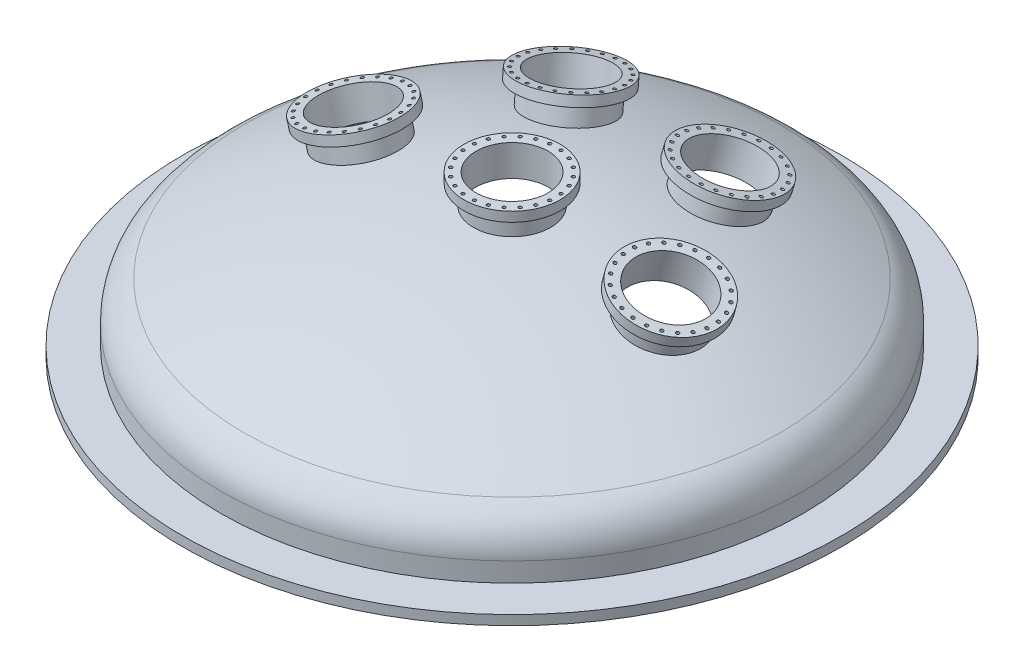
from build123d import *
from build123d.topology import SkipClean

# Parameters (mm, degrees)
REVOLVE6_ANGLE           = 180
REVOLVE7_ANGLE           = 180
CUT_EXTRUDE4_DEPTH       = 1301.690466813
SKETCH11_R               = 95.25
CUT_EXTRUDE5_DEPTH       = 1345.011112617
SKETCH12_R               = 95.25
CUT_EXTRUDE6_DEPTH       = 1233.519644311
CUT_EXTRUDE7_REACH       = 1302.69
SKETCH13_R               = 4.2164
CIRPATTERN1_COUNT        = 13
CIRPATTERN1_ANGLE        = 180
CUT_EXTRUDE8_REACH       = 1234.52
SKETCH15_R               = 4.2164
CIRPATTERN2_COUNT        = 24
CUT_EXTRUDE9_REACH       = 1346.011
SKETCH16_R               = 4.2164
CIRPATTERN3_COUNT        = 24
MIRROR2_COPY_1_REACH     = 1302.69
MIRROR2_COPY_1_SKETCH_R  = 4.2164
MIRROR2_COPY_2_REACH     = 1302.69
MIRROR2_COPY_2_SKETCH_R  = 4.2164
MIRROR2_COPY_3_REACH     = 1302.69
MIRROR2_COPY_3_SKETCH_R  = 4.2164
MIRROR2_COPY_4_REACH     = 1302.69
MIRROR2_COPY_4_SKETCH_R  = 4.2164
MIRROR2_COPY_5_REACH     = 1302.69
MIRROR2_COPY_5_SKETCH_R  = 4.2164
MIRROR2_COPY_6_REACH     = 1302.69
MIRROR2_COPY_6_SKETCH_R  = 4.2164
MIRROR2_COPY_7_REACH     = 1302.69
MIRROR2_COPY_7_SKETCH_R  = 4.2164
MIRROR2_COPY_8_REACH     = 1302.69
MIRROR2_COPY_8_SKETCH_R  = 4.2164
MIRROR2_COPY_9_REACH     = 1302.69
MIRROR2_COPY_9_SKETCH_R  = 4.2164
MIRROR2_COPY_10_REACH    = 1302.69
MIRROR2_COPY_10_SKETCH_R = 4.2164
MIRROR2_COPY_11_REACH    = 1302.69
MIRROR2_COPY_11_SKETCH_R = 4.2164
MIRROR2_COPY_12_REACH    = 1302.69
MIRROR2_COPY_12_SKETCH_R = 4.2164
MIRROR2_COPY_13_REACH    = 1234.52
MIRROR2_COPY_13_SKETCH_R = 4.2164
MIRROR2_COPY_14_REACH    = 1234.52
MIRROR2_COPY_14_SKETCH_R = 4.2164
MIRROR2_COPY_15_REACH    = 1234.52
MIRROR2_COPY_15_SKETCH_R = 4.2164
MIRROR2_COPY_16_REACH    = 1234.52
MIRROR2_COPY_16_SKETCH_R = 4.2164
MIRROR2_COPY_17_REACH    = 1234.52
MIRROR2_COPY_17_SKETCH_R = 4.2164
MIRROR2_COPY_18_REACH    = 1234.52
MIRROR2_COPY_18_SKETCH_R = 4.2164
MIRROR2_COPY_19_REACH    = 1234.52
MIRROR2_COPY_19_SKETCH_R = 4.2164
MIRROR2_COPY_20_REACH    = 1234.52
MIRROR2_COPY_20_SKETCH_R = 4.2164
MIRROR2_COPY_21_REACH    = 1234.52
MIRROR2_COPY_21_SKETCH_R = 4.2164
MIRROR2_COPY_22_REACH    = 1234.52
MIRROR2_COPY_22_SKETCH_R = 4.2164
MIRROR2_COPY_23_REACH    = 1234.52
MIRROR2_COPY_23_SKETCH_R = 4.2164
MIRROR2_COPY_24_REACH    = 1234.52
MIRROR2_COPY_24_SKETCH_R = 4.2164
MIRROR2_COPY_25_REACH    = 1234.52
MIRROR2_COPY_25_SKETCH_R = 4.2164
MIRROR2_COPY_26_REACH    = 1234.52
MIRROR2_COPY_26_SKETCH_R = 4.2164
MIRROR2_COPY_27_REACH    = 1234.52
MIRROR2_COPY_27_SKETCH_R = 4.2164
MIRROR2_COPY_28_REACH    = 1234.52
MIRROR2_COPY_28_SKETCH_R = 4.2164
MIRROR2_COPY_29_REACH    = 1234.52
MIRROR2_COPY_29_SKETCH_R = 4.2164
MIRROR2_COPY_30_REACH    = 1234.52
MIRROR2_COPY_30_SKETCH_R = 4.2164
MIRROR2_COPY_31_REACH    = 1234.52
MIRROR2_COPY_31_SKETCH_R = 4.2164
MIRROR2_COPY_32_REACH    = 1234.52
MIRROR2_COPY_32_SKETCH_R = 4.2164
MIRROR2_COPY_33_REACH    = 1234.52
MIRROR2_COPY_33_SKETCH_R = 4.2164
MIRROR2_COPY_34_REACH    = 1234.52
MIRROR2_COPY_34_SKETCH_R = 4.2164
MIRROR2_COPY_35_REACH    = 1234.52
MIRROR2_COPY_35_SKETCH_R = 4.2164
MIRROR2_COPY_36_REACH    = 1234.52
MIRROR2_COPY_36_SKETCH_R = 4.2164
MIRROR2_COPY_37_REACH    = 1346.011
MIRROR2_COPY_37_SKETCH_R = 4.2164
MIRROR2_COPY_38_REACH    = 1346.011
MIRROR2_COPY_38_SKETCH_R = 4.2164
MIRROR2_COPY_39_REACH    = 1346.011
MIRROR2_COPY_39_SKETCH_R = 4.2164
MIRROR2_COPY_40_REACH    = 1346.011
MIRROR2_COPY_40_SKETCH_R = 4.2164
MIRROR2_COPY_41_REACH    = 1346.011
MIRROR2_COPY_41_SKETCH_R = 4.2164
MIRROR2_COPY_42_REACH    = 1346.011
MIRROR2_COPY_42_SKETCH_R = 4.2164
MIRROR2_COPY_43_REACH    = 1346.011
MIRROR2_COPY_43_SKETCH_R = 4.2164
MIRROR2_COPY_44_REACH    = 1346.011
MIRROR2_COPY_44_SKETCH_R = 4.2164
MIRROR2_COPY_45_REACH    = 1346.011
MIRROR2_COPY_45_SKETCH_R = 4.2164
MIRROR2_COPY_46_REACH    = 1346.011
MIRROR2_COPY_46_SKETCH_R = 4.2164
MIRROR2_COPY_47_REACH    = 1346.011
MIRROR2_COPY_47_SKETCH_R = 4.2164
MIRROR2_COPY_48_REACH    = 1346.011
MIRROR2_COPY_48_SKETCH_R = 4.2164
MIRROR2_COPY_49_REACH    = 1346.011
MIRROR2_COPY_49_SKETCH_R = 4.2164
MIRROR2_COPY_50_REACH    = 1346.011
MIRROR2_COPY_50_SKETCH_R = 4.2164
MIRROR2_COPY_51_REACH    = 1346.011
MIRROR2_COPY_51_SKETCH_R = 4.2164
MIRROR2_COPY_52_REACH    = 1346.011
MIRROR2_COPY_52_SKETCH_R = 4.2164
MIRROR2_COPY_53_REACH    = 1346.011
MIRROR2_COPY_53_SKETCH_R = 4.2164
MIRROR2_COPY_54_REACH    = 1346.011
MIRROR2_COPY_54_SKETCH_R = 4.2164
MIRROR2_COPY_55_REACH    = 1346.011
MIRROR2_COPY_55_SKETCH_R = 4.2164
MIRROR2_COPY_56_REACH    = 1346.011
MIRROR2_COPY_56_SKETCH_R = 4.2164
MIRROR2_COPY_57_REACH    = 1346.011
MIRROR2_COPY_57_SKETCH_R = 4.2164
MIRROR2_COPY_58_REACH    = 1346.011
MIRROR2_COPY_58_SKETCH_R = 4.2164
MIRROR2_COPY_59_REACH    = 1346.011
MIRROR2_COPY_59_SKETCH_R = 4.2164
MIRROR2_COPY_60_REACH    = 1346.011
MIRROR2_COPY_60_SKETCH_R = 4.2164


with BuildPart() as part:
    # Sketch2 → Revolve6 (revolve)
    with BuildSketch(Plane.ZY):
        with BuildLine():
            Line((-762, 0), (-762, 76.2))
            ThreePointArc((-762, 76.2), (-746.146387828, 132.632796575), (-703.224203775, 172.553764303))
            ThreePointArc((-703.224203775, 172.553764303), (-361.781052845, 299.706397644), (0, 342.9))
            Line((0, 342.9), (0, 349.25))
            ThreePointArc((0, 349.25), (-363.276015874, 305.877911683), (-706.130088915, 178.199854238))
            ThreePointArc((-706.130088915, 178.199854238), (-751.567405751, 135.939617508), (-768.35, 76.2))
            Line((-768.35, 76.2), (-768.35, 25.4))
            Line((-768.35, 25.4), (-869.95, 25.4))
            Line((-869.95, 25.4), (-869.95, 0))
            Line((-869.95, 0), (-762, 0))
        make_face()
    revolve6 = revolve(axis=Axis((0, 0, 0), (0, 1, 0)), revolution_arc=REVOLVE6_ANGLE)

    # Sketch3 → Revolve7 (revolve)
    with BuildSketch(Plane(origin=(0, 0, 0), x_dir=(0, 0, -1), z_dir=(1, 0, 0))):
        with BuildLine():
            Line((101.6, 345.901510846), (101.6, 396.701510846))
            Line((101.6, 396.701510846), (127, 396.701510846))
            Line((127, 396.701510846), (127, 422.101510846))
            Line((127, 422.101510846), (0, 422.101510846))
            Line((0, 422.101510846), (0, 349.25))
            ThreePointArc((0, 349.25), (50.827582029, 348.412650514), (101.6, 345.901510846))
        make_face()
    revolve7 = revolve(axis=Axis((0, -136.02863292, 0), (0, 1, 0)), revolution_arc=REVOLVE7_ANGLE)

    # Sketch4 → Revolve8 (revolve)
    with BuildSketch(Plane.XY):
        with BuildLine():
            Line((-418.937428738, 366.850224604), (-541.595014732, 333.924298678))
            Line((-541.595014732, 333.924298678), (-535.009829547, 309.392781479))
            Line((-535.009829547, 309.392781479), (-510.478312348, 315.977966664))
            Line((-510.478312348, 315.977966664), (-497.307941978, 266.914932266))
            ThreePointArc((-497.307941978, 266.914932266), (-448.922582728, 282.503429928), (-400.05, 296.489669829))
            Line((-400.05, 296.489669829), (-418.937428738, 366.850224604))
        make_face()
    revolve8 = revolve(axis=Axis((-524.069555167, 758.494574021, 0), (0.2592592592592594, -0.9658077637337258, 0)))

    # Sketch6 → Revolve9 (revolve)
    with BuildSketch(Plane(origin=(-157.461606048, -21.143582215, 0), x_dir=(0, 0, -1), z_dir=(0.9911048584771088, 0.13308328032878555, 0)), mode=Mode.PRIVATE) as revolve9_sk:
        with BuildLine():
            Line((447.455484953, 293.567777013), (458.953427339, 343.049463735))
            Line((458.953427339, 343.049463735), (483.6942707, 337.300492541))
            Line((483.6942707, 337.300492541), (489.443241894, 362.041335902))
            Line((489.443241894, 362.041335902), (365.739025088, 390.786191869))
            Line((365.739025088, 390.786191869), (349.25, 319.825254135))
            ThreePointArc((349.25, 319.825254135), (398.569029422, 307.505449514), (447.455484953, 293.567777013))
        make_face()
    revolve9 = revolve(revolve9_sk.sketch.rotate(Axis((-200.025, 295.836781022, -349.25), (0.12962962962962968, -0.9653846479520914, 0.22633744855967086)), 178.259198398), axis=Axis((-200.025, 295.836781022, -349.25), (0.12962962962962968, -0.9653846479520914, 0.22633744855967086)))

    # Sketch10 → Cut-Extrude4 (cut, through all)
    with BuildSketch(Plane(origin=(0, 422.101510846, 0), x_dir=(-1, 0, 0), z_dir=(0, 1, 0))):
        with BuildLine():
            Line((0, 95.25), (0, -95.25))
            ThreePointArc((0, -95.25), (95.25, 0), (0, 95.25))
        make_face()
    cut_extrude4 = extrude(amount=-CUT_EXTRUDE4_DEPTH, mode=Mode.SUBTRACT)

    # Sketch11 → Cut-Extrude5 (cut, through all)
    with BuildSketch(Plane(origin=(-60.073652349, 447.383687586, -104.890504101), x_dir=(-0.9915624837205597, -0.12620733077213464, 0.02958970323081933), z_dir=(-0.12962962962962965, 0.9653846479520914, -0.22633744855967086))):
        with Locations(Location((150.666311476, -272.500876674, 0), (0, 0, 90))):
            Circle(SKETCH11_R)
    cut_extrude5 = extrude(amount=-CUT_EXTRUDE5_DEPTH, mode=Mode.SUBTRACT)

    # Sketch12 → Cut-Extrude6 (cut, through all)
    with BuildSketch(Plane(origin=(-120.016348796, 447.091925564, 0), x_dir=(-0.9658077637337257, -0.2592592592592595, 0), z_dir=(-0.2592592592592595, 0.9658077637337258, 0))):
        with Locations((309.503703704, 0)):
            Circle(SKETCH12_R)
    cut_extrude6 = extrude(amount=-CUT_EXTRUDE6_DEPTH, mode=Mode.SUBTRACT)

    # Sketch13 → Cut-Extrude7 (cut, up to next)
    with BuildSketch(Plane(origin=(0, 422.101510846, 0), x_dir=(-1, 0, 0), z_dir=(0, 1, 0)), mode=Mode.PRIVATE) as cut_extrude7_sk1:
        with Locations(Location((15.068335208, -114.455369132, 0), (0, 0, 90))):
            Circle(SKETCH13_R)
    cut_extrude7_tool1 = extrude(cut_extrude7_sk1.sketch, amount=-CUT_EXTRUDE7_REACH, mode=Mode.PRIVATE) & part.part
    cut_extrude7 = cut_extrude7_tool1.solids().sort_by_distance((-15.068335, 422.101511, -114.455369))[0]
    add(cut_extrude7, mode=Mode.SUBTRACT)

    # CirPattern1: Cut-Extrude7 ×13 about axis, 1 skipped
    cirpattern1_axis = Axis((0, 0, 0), (0, 1, 0))
    add([cut_extrude7.rotate(cirpattern1_axis, i * CIRPATTERN1_ANGLE / (CIRPATTERN1_COUNT - 1)) for i in range(1, CIRPATTERN1_COUNT) if i not in (12,)], mode=Mode.SUBTRACT)

    # Sketch15 → Cut-Extrude8 (cut, up to next)
    with BuildSketch(Plane(origin=(-120.016348796, 447.091925564, 0), x_dir=(-0.9658077637337257, -0.2592592592592595, 0), z_dir=(-0.2592592592592595, 0.9658077637337258, 0)), mode=Mode.PRIVATE) as cut_extrude8_sk1:
        with Locations((195.048334572, -15.068335208)):
            Circle(SKETCH15_R)
    cut_extrude8_tool1 = extrude(cut_extrude8_sk1.sketch, amount=-CUT_EXTRUDE8_REACH, mode=Mode.PRIVATE) & part.part
    cut_extrude8 = cut_extrude8_tool1.solids().sort_by_distance((-308.395545, 396.523839, -15.068335))[0]
    add(cut_extrude8, mode=Mode.SUBTRACT)

    # CirPattern2: Cut-Extrude8 ×24 about axis
    cirpattern2_axis = Axis((-298.921079941, -80.24170096, 0), (-0.25925925925925947, 0.9658077637337257, 0))
    for i in range(1, CIRPATTERN2_COUNT):
        add(cut_extrude8.rotate(cirpattern2_axis, i * 360 / CIRPATTERN2_COUNT), mode=Mode.SUBTRACT)

    # Sketch16 → Cut-Extrude9 (cut, up to next)
    with BuildSketch(Plane(origin=(-60.073652349, 447.383687586, -104.890504101), x_dir=(-0.9915624837205597, -0.12620733077213464, 0.02958970323081933), z_dir=(-0.12962962962962965, 0.9653846479520914, -0.22633744855967086)), mode=Mode.PRIVATE) as cut_extrude9_sk1:
        with Locations(Location((124.188690975, -160.13530427, 0), (0, 0, 90))):
            Circle(SKETCH16_R)
    cut_extrude9_tool1 = extrude(cut_extrude9_sk1.sketch, amount=-CUT_EXTRUDE9_REACH, mode=Mode.PRIVATE) & part.part
    cut_extrude9 = cut_extrude9_tool1.solids().sort_by_distance((-183.214499, 395.157131, -257.123435))[0]
    add(cut_extrude9, mode=Mode.SUBTRACT)

    # CirPattern3: Cut-Extrude9 ×24 about axis
    cirpattern3_axis = Axis((-149.39506202, -81.217176413, -260.848520987), (-0.12962962962962962, 0.9653846479520914, -0.2263374485596709))
    for i in range(1, CIRPATTERN3_COUNT):
        add(cut_extrude9.rotate(cirpattern3_axis, i * 360 / CIRPATTERN3_COUNT), mode=Mode.SUBTRACT)

    # Mirror2: Revolve6, Revolve7, Revolve8, Revolve9, Cut-Extrude4, Cut-Extrude5, Cut-Extrude6 across plane
    with SkipClean():  # the faces are left unmerged after this step: merging them gives an invalid solid
        add(revolve6.mirror(Plane(origin=(0, 0, 0), x_dir=(0, 0, 1), z_dir=(1, 0, 0))))
        add(revolve7.mirror(Plane(origin=(0, 0, 0), x_dir=(0, 0, 1), z_dir=(1, 0, 0))))
        add(revolve8.mirror(Plane(origin=(0, 0, 0), x_dir=(0, 0, 1), z_dir=(1, 0, 0))))
        add(revolve9.mirror(Plane(origin=(0, 0, 0), x_dir=(0, 0, 1), z_dir=(1, 0, 0))))
        add(cut_extrude4.mirror(Plane(origin=(0, 0, 0), x_dir=(0, 0, 1), z_dir=(1, 0, 0))), mode=Mode.SUBTRACT)
        add(cut_extrude5.mirror(Plane(origin=(0, 0, 0), x_dir=(0, 0, 1), z_dir=(1, 0, 0))), mode=Mode.SUBTRACT)
        add(cut_extrude6.mirror(Plane(origin=(0, 0, 0), x_dir=(0, 0, 1), z_dir=(1, 0, 0))), mode=Mode.SUBTRACT)

    # Mirror2 copy 1 sketch → Mirror2 copy 1 (cut, up to next)
    with BuildSketch(Plane(origin=(0, 422.101510846, 0), x_dir=(0.9659258262890681, 0, 0.25881904510252135), z_dir=(0, 1, 0)), mode=Mode.PRIVATE) as mirror2_copy_1_sk1:
        with Locations((15.068335208, 114.455369132)):
            Circle(MIRROR2_COPY_1_SKETCH_R)
    mirror2_copy_1_tool1 = extrude(mirror2_copy_1_sk1.sketch, amount=-MIRROR2_COPY_1_REACH, mode=Mode.PRIVATE) & part.part
    add(mirror2_copy_1_tool1.solids().sort_by_distance((44.178123247, 422.101511, -106.655424799))[0], mode=Mode.SUBTRACT)

    # Mirror2 copy 2 sketch → Mirror2 copy 2 (cut, up to next)
    with BuildSketch(Plane(origin=(0, 422.101510846, 0), x_dir=(0.866025403784438, 0, 0.500000000000001), z_dir=(0, 1, 0)), mode=Mode.PRIVATE) as mirror2_copy_2_sk1:
        with Locations((15.068335208, 114.455369132)):
            Circle(MIRROR2_COPY_2_SKETCH_R)
    mirror2_copy_2_tool1 = extrude(mirror2_copy_2_sk1.sketch, amount=-MIRROR2_COPY_2_REACH, mode=Mode.PRIVATE) & part.part
    add(mirror2_copy_2_tool1.solids().sort_by_distance((70.277245403, 422.101511, -91.587089654))[0], mode=Mode.SUBTRACT)

    # Mirror2 copy 3 sketch → Mirror2 copy 3 (cut, up to next)
    with BuildSketch(Plane(origin=(0, 422.101510846, 0), x_dir=(0.7071067811865462, 0, 0.7071067811865488), z_dir=(0, 1, 0)), mode=Mode.PRIVATE) as mirror2_copy_3_sk1:
        with Locations((15.068335208, 114.455369132)):
            Circle(MIRROR2_COPY_3_SKETCH_R)
    mirror2_copy_3_tool1 = extrude(mirror2_copy_3_sk1.sketch, amount=-MIRROR2_COPY_3_REACH, mode=Mode.PRIVATE) & part.part
    add(mirror2_copy_3_tool1.solids().sort_by_distance((91.587089423, 422.101511, -70.277245703))[0], mode=Mode.SUBTRACT)

    # Mirror2 copy 4 sketch → Mirror2 copy 4 (cut, up to next)
    with BuildSketch(Plane(origin=(0, 422.101510846, 0), x_dir=(0.499999999999998, 0, 0.8660254037844398), z_dir=(0, 1, 0)), mode=Mode.PRIVATE) as mirror2_copy_4_sk1:
        with Locations((15.068335208, 114.455369132)):
            Circle(MIRROR2_COPY_4_SKETCH_R)
    mirror2_copy_4_tool1 = extrude(mirror2_copy_4_sk1.sketch, amount=-MIRROR2_COPY_4_REACH, mode=Mode.PRIVATE) & part.part
    add(mirror2_copy_4_tool1.solids().sort_by_distance((106.655424654, 422.101511, -44.178123597))[0], mode=Mode.SUBTRACT)

    # Mirror2 copy 5 sketch → Mirror2 copy 5 (cut, up to next)
    with BuildSketch(Plane(origin=(0, 422.101510846, 0), x_dir=(0.25881904510251796, 0, 0.9659258262890691), z_dir=(0, 1, 0)), mode=Mode.PRIVATE) as mirror2_copy_5_sk1:
        with Locations((15.068335208, 114.455369132)):
            Circle(MIRROR2_COPY_5_SKETCH_R)
    mirror2_copy_5_tool1 = extrude(mirror2_copy_5_sk1.sketch, amount=-MIRROR2_COPY_5_REACH, mode=Mode.PRIVATE) & part.part
    add(mirror2_copy_5_tool1.solids().sort_by_distance((114.455368951, 422.101511, -15.068335376))[0], mode=Mode.SUBTRACT)

    # Mirror2 copy 6 sketch → Mirror2 copy 6 (cut, up to next)
    with BuildSketch(Plane.ZX.offset(422.101510846), mode=Mode.PRIVATE) as mirror2_copy_6_sk1:
        with Locations((15.068335208, 114.455369132)):
            Circle(MIRROR2_COPY_6_SKETCH_R)
    mirror2_copy_6_tool1 = extrude(mirror2_copy_6_sk1.sketch, amount=-MIRROR2_COPY_6_REACH, mode=Mode.PRIVATE) & part.part
    add(mirror2_copy_6_tool1.solids().sort_by_distance((114.455369, 422.101511, 15.068335))[0], mode=Mode.SUBTRACT)

    # Mirror2 copy 7 sketch → Mirror2 copy 7 (cut, up to next)
    with BuildSketch(Plane(origin=(0, 422.101510846, 0), x_dir=(-0.2588190451025249, 0, 0.9659258262890672), z_dir=(0, 1, 0)), mode=Mode.PRIVATE) as mirror2_copy_7_sk1:
        with Locations((15.068335208, 114.455369132)):
            Circle(MIRROR2_COPY_7_SKETCH_R)
    mirror2_copy_7_tool1 = extrude(mirror2_copy_7_sk1.sketch, amount=-MIRROR2_COPY_7_REACH, mode=Mode.PRIVATE) & part.part
    add(mirror2_copy_7_tool1.solids().sort_by_distance((106.655424799, 422.101511, 44.178123247))[0], mode=Mode.SUBTRACT)

    # Mirror2 copy 8 sketch → Mirror2 copy 8 (cut, up to next)
    with BuildSketch(Plane(origin=(0, 422.101510846, 0), x_dir=(-0.500000000000004, 0, 0.8660254037844363), z_dir=(0, 1, 0)), mode=Mode.PRIVATE) as mirror2_copy_8_sk1:
        with Locations((15.068335208, 114.455369132)):
            Circle(MIRROR2_COPY_8_SKETCH_R)
    mirror2_copy_8_tool1 = extrude(mirror2_copy_8_sk1.sketch, amount=-MIRROR2_COPY_8_REACH, mode=Mode.PRIVATE) & part.part
    add(mirror2_copy_8_tool1.solids().sort_by_distance((91.587089654, 422.101511, 70.277245403))[0], mode=Mode.SUBTRACT)

    # Mirror2 copy 9 sketch → Mirror2 copy 9 (cut, up to next)
    with BuildSketch(Plane(origin=(0, 422.101510846, 0), x_dir=(-0.7071067811865512, 0, 0.7071067811865438), z_dir=(0, 1, 0)), mode=Mode.PRIVATE) as mirror2_copy_9_sk1:
        with Locations((15.068335208, 114.455369132)):
            Circle(MIRROR2_COPY_9_SKETCH_R)
    mirror2_copy_9_tool1 = extrude(mirror2_copy_9_sk1.sketch, amount=-MIRROR2_COPY_9_REACH, mode=Mode.PRIVATE) & part.part
    add(mirror2_copy_9_tool1.solids().sort_by_distance((70.277245703, 422.101511, 91.587089423))[0], mode=Mode.SUBTRACT)

    # Mirror2 copy 10 sketch → Mirror2 copy 10 (cut, up to next)
    with BuildSketch(Plane(origin=(0, 422.101510846, 0), x_dir=(-0.8660254037844416, 0, 0.49999999999999495), z_dir=(0, 1, 0)), mode=Mode.PRIVATE) as mirror2_copy_10_sk1:
        with Locations((15.068335208, 114.455369132)):
            Circle(MIRROR2_COPY_10_SKETCH_R)
    mirror2_copy_10_tool1 = extrude(mirror2_copy_10_sk1.sketch, amount=-MIRROR2_COPY_10_REACH, mode=Mode.PRIVATE) & part.part
    add(mirror2_copy_10_tool1.solids().sort_by_distance((44.178123597, 422.101511, 106.655424654))[0], mode=Mode.SUBTRACT)

    # Mirror2 copy 11 sketch → Mirror2 copy 11 (cut, up to next)
    with BuildSketch(Plane(origin=(0, 422.101510846, 0), x_dir=(-0.96592582628907, 0, 0.2588190451025146), z_dir=(0, 1, 0)), mode=Mode.PRIVATE) as mirror2_copy_11_sk1:
        with Locations((15.068335208, 114.455369132)):
            Circle(MIRROR2_COPY_11_SKETCH_R)
    mirror2_copy_11_tool1 = extrude(mirror2_copy_11_sk1.sketch, amount=-MIRROR2_COPY_11_REACH, mode=Mode.PRIVATE) & part.part
    add(mirror2_copy_11_tool1.solids().sort_by_distance((15.068335376, 422.101511, 114.455368951))[0], mode=Mode.SUBTRACT)

    # Mirror2 copy 12 sketch → Mirror2 copy 12 (cut, up to next)
    with BuildSketch(Plane(origin=(0, 422.101510846, 0), x_dir=(1, 0, 0), z_dir=(0, 1, 0)), mode=Mode.PRIVATE) as mirror2_copy_12_sk1:
        with Locations((15.068335208, 114.455369132)):
            Circle(MIRROR2_COPY_12_SKETCH_R)
    mirror2_copy_12_tool1 = extrude(mirror2_copy_12_sk1.sketch, amount=-MIRROR2_COPY_12_REACH, mode=Mode.PRIVATE) & part.part
    add(mirror2_copy_12_tool1.solids().sort_by_distance((15.068335, 422.101511, -114.455369))[0], mode=Mode.SUBTRACT)

    # Mirror2 copy 13 sketch → Mirror2 copy 13 (cut, up to next)
    with BuildSketch(Plane(origin=(130.2018376, 444.357755907, -80.105453048), x_dir=(0.9328986622208962, -0.250425214223092, 0.25881904510252074), z_dir=(0.2592592592592595, 0.9658077637337258, 0)), mode=Mode.PRIVATE) as mirror2_copy_13_sk1:
        with Locations((195.048334572, 15.068335208)):
            Circle(MIRROR2_COPY_13_SKETCH_R)
    mirror2_copy_13_tool1 = extrude(mirror2_copy_13_sk1.sketch, amount=-MIRROR2_COPY_13_REACH, mode=Mode.PRIVATE) & part.part
    add(mirror2_copy_13_tool1.solids().sort_by_distance((315.928791661, 394.501631246, -44.1781232))[0], mode=Mode.SUBTRACT)

    # Mirror2 copy 14 sketch → Mirror2 copy 14 (cut, up to next)
    with BuildSketch(Plane(origin=(160.064179782, 436.341576078, -154.751851852), x_dir=(0.8364140585656455, -0.2245251046848547, 0.49999999999999994), z_dir=(0.2592592592592595, 0.9658077637337258, 0)), mode=Mode.PRIVATE) as mirror2_copy_14_sk1:
        with Locations((195.048334572, 15.068335208)):
            Circle(MIRROR2_COPY_14_SKETCH_R)
    mirror2_copy_14_tool1 = extrude(mirror2_copy_14_sk1.sketch, amount=-MIRROR2_COPY_14_REACH, mode=Mode.PRIVATE) & part.part
    add(mirror2_copy_14_tool1.solids().sort_by_distance((330.481906713, 390.595025842, -70.277245313))[0], mode=Mode.SUBTRACT)

    # Mirror2 copy 15 sketch → Mirror2 copy 15 (cut, up to next)
    with BuildSketch(Plane(origin=(207.568306072, 423.589675487, -218.852167691), x_dir=(0.6829292190587324, -0.18332398030762367, 0.7071067811865474), z_dir=(0.2592592592592595, 0.9658077637337259, 0)), mode=Mode.PRIVATE) as mirror2_copy_15_sk1:
        with Locations((195.048334572, 15.068335208)):
            Circle(MIRROR2_COPY_15_SKETCH_R)
    mirror2_copy_15_tool1 = extrude(mirror2_copy_15_sk1.sketch, amount=-MIRROR2_COPY_15_REACH, mode=Mode.PRIVATE) & part.part
    add(mirror2_copy_15_tool1.solids().sort_by_distance((351.063119416, 385.070251492, -91.587089295))[0], mode=Mode.SUBTRACT)

    # Mirror2 copy 16 sketch → Mirror2 copy 16 (cut, up to next)
    with BuildSketch(Plane(origin=(269.476888767, 406.971075084, -268.038069973), x_dir=(0.48290388186686295, -0.1296296296296298, 0.8660254037844386), z_dir=(0.2592592592592595, 0.9658077637337258, 0)), mode=Mode.PRIVATE) as mirror2_copy_16_sk1:
        with Locations((195.048334572, 15.068335208)):
            Circle(MIRROR2_COPY_16_SKETCH_R)
    mirror2_copy_16_tool1 = extrude(mirror2_copy_16_sk1.sketch, amount=-MIRROR2_COPY_16_REACH, mode=Mode.PRIVATE) & part.part
    add(mirror2_copy_16_tool1.solids().sort_by_distance((376.269854137, 378.303812437, -106.655424497))[0], mode=Mode.SUBTRACT)

    # Mirror2 copy 17 sketch → Mirror2 copy 17 (cut, up to next)
    with BuildSketch(Plane(origin=(341.570960266, 387.618305024, -298.95762074), x_dir=(0.2499694431621638, -0.06710123391546843, 0.9659258262890684), z_dir=(0.2592592592592595, 0.9658077637337258, 0)), mode=Mode.PRIVATE) as mirror2_copy_17_sk1:
        with Locations((195.048334572, 15.068335208)):
            Circle(MIRROR2_COPY_17_SKETCH_R)
    mirror2_copy_17_tool1 = extrude(mirror2_copy_17_sk1.sketch, amount=-MIRROR2_COPY_17_REACH, mode=Mode.PRIVATE) & part.part
    add(mirror2_copy_17_tool1.solids().sort_by_distance((404.38431356, 370.756830317, -114.455368776))[0], mode=Mode.SUBTRACT)

    # Mirror2 copy 18 sketch → Mirror2 copy 18 (cut, up to next)
    with BuildSketch(Plane(origin=(418.937428738, 366.850224604, -309.503703704), x_dir=(0, 0, 1), z_dir=(0.25925925925925947, 0.9658077637337258, 0)), mode=Mode.PRIVATE) as mirror2_copy_18_sk1:
        with Locations((195.048334572, 15.068335208)):
            Circle(MIRROR2_COPY_18_SKETCH_R)
    mirror2_copy_18_tool1 = extrude(mirror2_copy_18_sk1.sketch, amount=-MIRROR2_COPY_18_REACH, mode=Mode.PRIVATE) & part.part
    add(mirror2_copy_18_tool1.solids().sort_by_distance((433.490543737, 362.943619491, -114.45536882))[0], mode=Mode.SUBTRACT)

    # Mirror2 copy 19 sketch → Mirror2 copy 19 (cut, up to next)
    with BuildSketch(Plane(origin=(496.303897209, 346.082144184, -298.95762074), x_dir=(-0.24996944316216396, 0.06710123391546835, 0.9659258262890684), z_dir=(0.2592592592592595, 0.9658077637337258, 0)), mode=Mode.PRIVATE) as mirror2_copy_19_sk1:
        with Locations((195.048334572, 15.068335208)):
            Circle(MIRROR2_COPY_19_SKETCH_R)
    mirror2_copy_19_tool1 = extrude(mirror2_copy_19_sk1.sketch, amount=-MIRROR2_COPY_19_REACH, mode=Mode.PRIVATE) & part.part
    add(mirror2_copy_19_tool1.solids().sort_by_distance((461.605003181, 355.396637365, -106.655424624))[0], mode=Mode.SUBTRACT)

    # Mirror2 copy 20 sketch → Mirror2 copy 20 (cut, up to next)
    with BuildSketch(Plane(origin=(568.397968708, 326.729374124, -268.038069973), x_dir=(-0.4829038818668626, 0.12962962962962968, 0.8660254037844387), z_dir=(0.2592592592592595, 0.9658077637337258, 0)), mode=Mode.PRIVATE) as mirror2_copy_20_sk1:
        with Locations((195.048334572, 15.068335208)):
            Circle(MIRROR2_COPY_20_SKETCH_R)
    mirror2_copy_20_tool1 = extrude(mirror2_copy_20_sk1.sketch, amount=-MIRROR2_COPY_20_REACH, mode=Mode.PRIVATE) & part.part
    add(mirror2_copy_20_tool1.solids().sort_by_distance((486.811737944, 348.630198299, -91.587089497))[0], mode=Mode.SUBTRACT)

    # Mirror2 copy 21 sketch → Mirror2 copy 21 (cut, up to next)
    with BuildSketch(Plane(origin=(630.306551404, 310.110773721, -218.852167691), x_dir=(-0.6829292190587324, 0.1833239803076236, 0.7071067811865475), z_dir=(0.2592592592592595, 0.9658077637337258, 0)), mode=Mode.PRIVATE) as mirror2_copy_21_sk1:
        with Locations((195.048334572, 15.068335208)):
            Circle(MIRROR2_COPY_21_SKETCH_R)
    mirror2_copy_21_tool1 = extrude(mirror2_copy_21_sk1.sketch, amount=-MIRROR2_COPY_21_REACH, mode=Mode.PRIVATE) & part.part
    add(mirror2_copy_21_tool1.solids().sort_by_distance((507.392950706, 343.105423933, -70.277245576))[0], mode=Mode.SUBTRACT)

    # Mirror2 copy 22 sketch → Mirror2 copy 22 (cut, up to next)
    with BuildSketch(Plane(origin=(677.810677694, 297.358873129, -154.751851852), x_dir=(-0.8364140585656457, 0.22452510468485465, 0.49999999999999994), z_dir=(0.2592592592592595, 0.965807763733726, 0)), mode=Mode.PRIVATE) as mirror2_copy_22_sk1:
        with Locations((195.048334572, 15.068335208)):
            Circle(MIRROR2_COPY_22_SKETCH_R)
    mirror2_copy_22_tool1 = extrude(mirror2_copy_22_sk1.sketch, amount=-MIRROR2_COPY_22_REACH, mode=Mode.PRIVATE) & part.part
    add(mirror2_copy_22_tool1.solids().sort_by_distance((521.946065831, 339.19881851, -44.178123507))[0], mode=Mode.SUBTRACT)

    # Mirror2 copy 23 sketch → Mirror2 copy 23 (cut, up to next)
    with BuildSketch(Plane(origin=(707.673019875, 289.342693301, -80.105453048), x_dir=(-0.9328986622208961, 0.25042521422309194, 0.258819045102521), z_dir=(0.2592592592592595, 0.9658077637337259, 0)), mode=Mode.PRIVATE) as mirror2_copy_23_sk1:
        with Locations((195.048334572, 15.068335208)):
            Circle(MIRROR2_COPY_23_SKETCH_R)
    mirror2_copy_23_tool1 = extrude(mirror2_copy_23_sk1.sketch, amount=-MIRROR2_COPY_23_REACH, mode=Mode.PRIVATE) & part.part
    add(mirror2_copy_23_tool1.solids().sort_by_distance((529.479312572, 337.176610734, -15.068335329))[0], mode=Mode.SUBTRACT)

    # Mirror2 copy 24 sketch → Mirror2 copy 24 (cut, up to next)
    with BuildSketch(Plane(origin=(717.858508679, 286.608523643, 0), x_dir=(-0.9658077637337258, 0.2592592592592594, 0), z_dir=(0.2592592592592595, 0.9658077637337259, 0)), mode=Mode.PRIVATE) as mirror2_copy_24_sk1:
        with Locations((195.048334572, 15.068335208)):
            Circle(MIRROR2_COPY_24_SKETCH_R)
    mirror2_copy_24_tool1 = extrude(mirror2_copy_24_sk1.sketch, amount=-MIRROR2_COPY_24_REACH, mode=Mode.PRIVATE) & part.part
    add(mirror2_copy_24_tool1.solids().sort_by_distance((529.479312614, 337.176610723, 15.068335))[0], mode=Mode.SUBTRACT)

    # Mirror2 copy 25 sketch → Mirror2 copy 25 (cut, up to next)
    with BuildSketch(Plane(origin=(707.673019875, 289.342693301, 80.105453048), x_dir=(-0.9328986622208963, 0.25042521422309194, -0.2588190451025208), z_dir=(0.25925925925925947, 0.9658077637337257, 0)), mode=Mode.PRIVATE) as mirror2_copy_25_sk1:
        with Locations((195.048334572, 15.068335208)):
            Circle(MIRROR2_COPY_25_SKETCH_R)
    mirror2_copy_25_tool1 = extrude(mirror2_copy_25_sk1.sketch, amount=-MIRROR2_COPY_25_REACH, mode=Mode.PRIVATE) & part.part
    add(mirror2_copy_25_tool1.solids().sort_by_distance((521.946065953, 339.198818478, 44.1781232))[0], mode=Mode.SUBTRACT)

    # Mirror2 copy 26 sketch → Mirror2 copy 26 (cut, up to next)
    with BuildSketch(Plane(origin=(677.810677694, 297.358873129, 154.751851852), x_dir=(-0.8364140585656454, 0.22452510468485462, -0.5000000000000001), z_dir=(0.2592592592592595, 0.9658077637337259, 0)), mode=Mode.PRIVATE) as mirror2_copy_26_sk1:
        with Locations((195.048334572, 15.068335208)):
            Circle(MIRROR2_COPY_26_SKETCH_R)
    mirror2_copy_26_tool1 = extrude(mirror2_copy_26_sk1.sketch, amount=-MIRROR2_COPY_26_REACH, mode=Mode.PRIVATE) & part.part
    add(mirror2_copy_26_tool1.solids().sort_by_distance((507.392950901, 343.105423881, 70.277245313))[0], mode=Mode.SUBTRACT)

    # Mirror2 copy 27 sketch → Mirror2 copy 27 (cut, up to next)
    with BuildSketch(Plane(origin=(630.306551404, 310.110773721, 218.852167691), x_dir=(-0.6829292190587326, 0.18332398030762365, -0.7071067811865474), z_dir=(0.2592592592592595, 0.9658077637337258, 0)), mode=Mode.PRIVATE) as mirror2_copy_27_sk1:
        with Locations((195.048334572, 15.068335208)):
            Circle(MIRROR2_COPY_27_SKETCH_R)
    mirror2_copy_27_tool1 = extrude(mirror2_copy_27_sk1.sketch, amount=-MIRROR2_COPY_27_REACH, mode=Mode.PRIVATE) & part.part
    add(mirror2_copy_27_tool1.solids().sort_by_distance((486.811738198, 348.630198231, 91.587089295))[0], mode=Mode.SUBTRACT)

    # Mirror2 copy 28 sketch → Mirror2 copy 28 (cut, up to next)
    with BuildSketch(Plane(origin=(568.397968708, 326.729374124, 268.038069973), x_dir=(-0.48290388186686334, 0.12962962962962984, -0.8660254037844384), z_dir=(0.2592592592592595, 0.9658077637337258, 0)), mode=Mode.PRIVATE) as mirror2_copy_28_sk1:
        with Locations((195.048334572, 15.068335208)):
            Circle(MIRROR2_COPY_28_SKETCH_R)
    mirror2_copy_28_tool1 = extrude(mirror2_copy_28_sk1.sketch, amount=-MIRROR2_COPY_28_REACH, mode=Mode.PRIVATE) & part.part
    add(mirror2_copy_28_tool1.solids().sort_by_distance((461.605003477, 355.396637286, 106.655424497))[0], mode=Mode.SUBTRACT)

    # Mirror2 copy 29 sketch → Mirror2 copy 29 (cut, up to next)
    with BuildSketch(Plane(origin=(496.303897209, 346.082144184, 298.95762074), x_dir=(-0.24996944316216377, 0.0671012339154683, -0.9659258262890684), z_dir=(0.2592592592592596, 0.965807763733726, 0)), mode=Mode.PRIVATE) as mirror2_copy_29_sk1:
        with Locations((195.048334572, 15.068335208)):
            Circle(MIRROR2_COPY_29_SKETCH_R)
    mirror2_copy_29_tool1 = extrude(mirror2_copy_29_sk1.sketch, amount=-MIRROR2_COPY_29_REACH, mode=Mode.PRIVATE) & part.part
    add(mirror2_copy_29_tool1.solids().sort_by_distance((433.490544054, 362.943619406, 114.455368776))[0], mode=Mode.SUBTRACT)

    # Mirror2 copy 30 sketch → Mirror2 copy 30 (cut, up to next)
    with BuildSketch(Plane(origin=(418.937428738, 366.850224604, 309.503703704), x_dir=(0, 0, -1), z_dir=(0.2592592592592595, 0.9658077637337258, 0)), mode=Mode.PRIVATE) as mirror2_copy_30_sk1:
        with Locations((195.048334572, 15.068335208)):
            Circle(MIRROR2_COPY_30_SKETCH_R)
    mirror2_copy_30_tool1 = extrude(mirror2_copy_30_sk1.sketch, amount=-MIRROR2_COPY_30_REACH, mode=Mode.PRIVATE) & part.part
    add(mirror2_copy_30_tool1.solids().sort_by_distance((404.384313877, 370.756830232, 114.45536882))[0], mode=Mode.SUBTRACT)

    # Mirror2 copy 31 sketch → Mirror2 copy 31 (cut, up to next)
    with BuildSketch(Plane(origin=(341.570960266, 387.618305024, 298.95762074), x_dir=(0.24996944316216343, -0.06710123391546832, -0.9659258262890684), z_dir=(0.2592592592592595, 0.9658077637337258, 0)), mode=Mode.PRIVATE) as mirror2_copy_31_sk1:
        with Locations((195.048334572, 15.068335208)):
            Circle(MIRROR2_COPY_31_SKETCH_R)
    mirror2_copy_31_tool1 = extrude(mirror2_copy_31_sk1.sketch, amount=-MIRROR2_COPY_31_REACH, mode=Mode.PRIVATE) & part.part
    add(mirror2_copy_31_tool1.solids().sort_by_distance((376.269854433, 378.303812358, 106.655424624))[0], mode=Mode.SUBTRACT)

    # Mirror2 copy 32 sketch → Mirror2 copy 32 (cut, up to next)
    with BuildSketch(Plane(origin=(269.476888767, 406.971075084, 268.038069973), x_dir=(0.48290388186686295, -0.1296296296296298, -0.8660254037844386), z_dir=(0.2592592592592595, 0.9658077637337258, 0)), mode=Mode.PRIVATE) as mirror2_copy_32_sk1:
        with Locations((195.048334572, 15.068335208)):
            Circle(MIRROR2_COPY_32_SKETCH_R)
    mirror2_copy_32_tool1 = extrude(mirror2_copy_32_sk1.sketch, amount=-MIRROR2_COPY_32_REACH, mode=Mode.PRIVATE) & part.part
    add(mirror2_copy_32_tool1.solids().sort_by_distance((351.06311967, 385.070251424, 91.587089497))[0], mode=Mode.SUBTRACT)

    # Mirror2 copy 33 sketch → Mirror2 copy 33 (cut, up to next)
    with BuildSketch(Plane(origin=(207.568306072, 423.589675487, 218.852167691), x_dir=(0.6829292190587322, -0.1833239803076236, -0.7071067811865477), z_dir=(0.2592592592592595, 0.9658077637337258, 0)), mode=Mode.PRIVATE) as mirror2_copy_33_sk1:
        with Locations((195.048334572, 15.068335208)):
            Circle(MIRROR2_COPY_33_SKETCH_R)
    mirror2_copy_33_tool1 = extrude(mirror2_copy_33_sk1.sketch, amount=-MIRROR2_COPY_33_REACH, mode=Mode.PRIVATE) & part.part
    add(mirror2_copy_33_tool1.solids().sort_by_distance((330.481906908, 390.59502579, 70.277245576))[0], mode=Mode.SUBTRACT)

    # Mirror2 copy 34 sketch → Mirror2 copy 34 (cut, up to next)
    with BuildSketch(Plane(origin=(160.064179782, 436.341576078, 154.751851852), x_dir=(0.8364140585656452, -0.22452510468485462, -0.5000000000000004), z_dir=(0.2592592592592595, 0.9658077637337258, 0)), mode=Mode.PRIVATE) as mirror2_copy_34_sk1:
        with Locations((195.048334572, 15.068335208)):
            Circle(MIRROR2_COPY_34_SKETCH_R)
    mirror2_copy_34_tool1 = extrude(mirror2_copy_34_sk1.sketch, amount=-MIRROR2_COPY_34_REACH, mode=Mode.PRIVATE) & part.part
    add(mirror2_copy_34_tool1.solids().sort_by_distance((315.928791783, 394.501631213, 44.178123507))[0], mode=Mode.SUBTRACT)

    # Mirror2 copy 35 sketch → Mirror2 copy 35 (cut, up to next)
    with BuildSketch(Plane(origin=(130.2018376, 444.357755907, 80.105453048), x_dir=(0.9328986622208962, -0.250425214223092, -0.2588190451025207), z_dir=(0.2592592592592595, 0.9658077637337258, 0)), mode=Mode.PRIVATE) as mirror2_copy_35_sk1:
        with Locations((195.048334572, 15.068335208)):
            Circle(MIRROR2_COPY_35_SKETCH_R)
    mirror2_copy_35_tool1 = extrude(mirror2_copy_35_sk1.sketch, amount=-MIRROR2_COPY_35_REACH, mode=Mode.PRIVATE) & part.part
    add(mirror2_copy_35_tool1.solids().sort_by_distance((308.395545042, 396.523838989, 15.068335329))[0], mode=Mode.SUBTRACT)

    # Mirror2 copy 36 sketch → Mirror2 copy 36 (cut, up to next)
    with BuildSketch(Plane(origin=(120.016348796, 447.091925564, 0), x_dir=(0.9658077637337257, -0.2592592592592595, 0), z_dir=(0.2592592592592595, 0.9658077637337258, 0)), mode=Mode.PRIVATE) as mirror2_copy_36_sk1:
        with Locations((195.048334572, 15.068335208)):
            Circle(MIRROR2_COPY_36_SKETCH_R)
    mirror2_copy_36_tool1 = extrude(mirror2_copy_36_sk1.sketch, amount=-MIRROR2_COPY_36_REACH, mode=Mode.PRIVATE) & part.part
    add(mirror2_copy_36_tool1.solids().sort_by_distance((308.395545, 396.523839, -15.068335))[0], mode=Mode.SUBTRACT)

    # Mirror2 copy 37 sketch → Mirror2 copy 37 (cut, up to next)
    with BuildSketch(Plane(origin=(-4.769166383, 444.616279408, -153.831428442), x_dir=(0.9577758114050224, -0.06282799858929018, 0.2805675278443947), z_dir=(0.12962962962962962, 0.9653846479520914, -0.22633744855967086)), mode=Mode.PRIVATE) as mirror2_copy_37_sk1:
        with Locations((124.188690975, 160.13530427)):
            Circle(MIRROR2_COPY_37_SKETCH_R)
    mirror2_copy_37_tool1 = extrude(mirror2_copy_37_sk1.sketch, amount=-MIRROR2_COPY_37_REACH, mode=Mode.PRIVATE) & part.part
    add(mirror2_copy_37_tool1.solids().sort_by_distance((155.272122327, 396.27543608, -268.356951148))[0], mode=Mode.SUBTRACT)

    # Mirror2 copy 38 sketch → Mirror2 copy 38 (cut, up to next)
    with BuildSketch(Plane(origin=(-55.012027586, 436.50264917, -217.2135053), x_dir=(0.8587183003415986, 0.004832957869237559, 0.5124251390951369), z_dir=(0.12962962962962965, 0.9653846479520914, -0.22633744855967086)), mode=Mode.PRIVATE) as mirror2_copy_38_sk1:
        with Locations((124.188690975, 160.13530427)):
            Circle(MIRROR2_COPY_38_SKETCH_R)
    mirror2_copy_38_tool1 = extrude(mirror2_copy_38_sk1.sketch, amount=-MIRROR2_COPY_38_REACH, mode=Mode.PRIVATE) & part.part
    add(mirror2_copy_38_tool1.solids().sort_by_distance((131.023153834, 395.341867656, -286.226894698))[0], mode=Mode.SUBTRACT)

    # Mirror2 copy 39 sketch → Mirror2 copy 39 (cut, up to next)
    with BuildSketch(Plane(origin=(-87.2309633, 423.595727363, -290.717350882), x_dir=(0.7011405562089835, 0.07216455623581731, 0.7093618239391272), z_dir=(0.12962962962962965, 0.9653846479520914, -0.22633744855967086)), mode=Mode.PRIVATE) as mirror2_copy_39_sk1:
        with Locations((124.188690975, 160.13530427)):
            Circle(MIRROR2_COPY_39_SKETCH_R)
    mirror2_copy_39_tool1 = extrude(mirror2_copy_39_sk1.sketch, amount=-MIRROR2_COPY_39_REACH, mode=Mode.PRIVATE) & part.part
    add(mirror2_copy_39_tool1.solids().sort_by_distance((112.12012065, 392.420046874, -309.515458526))[0], mode=Mode.SUBTRACT)

    # Mirror2 copy 40 sketch → Mirror2 copy 40 (cut, up to next)
    with BuildSketch(Plane(origin=(-99.2303063, 406.775099379, -369.333799581), x_dir=(0.49578124186028, 0.13457825935249393, 0.8579566727575069), z_dir=(0.12962962962962965, 0.9653846479520917, -0.2263374485596708)), mode=Mode.PRIVATE) as mirror2_copy_40_sk1:
        with Locations((124.188690975, 160.13530427)):
            Circle(MIRROR2_COPY_40_SKETCH_R)
    mirror2_copy_40_tool1 = extrude(mirror2_copy_40_sk1.sketch, amount=-MIRROR2_COPY_40_REACH, mode=Mode.PRIVATE) & part.part
    add(mirror2_copy_40_tool1.solids().sort_by_distance((99.851233248, 387.709090991, -336.635565496))[0], mode=Mode.SUBTRACT)

    # Mirror2 copy 41 sketch → Mirror2 copy 41 (cut, up to next)
    with BuildSketch(Plane(origin=(-90.192321191, 387.187063218, -447.70527034), x_dir=(0.256635255196039, 0.18782067649538722, 0.9480831921679022), z_dir=(0.12962962962962965, 0.9653846479520916, -0.22633744855967092)), mode=Mode.PRIVATE) as mirror2_copy_41_sk1:
        with Locations((124.188690975, 160.13530427)):
            Circle(MIRROR2_COPY_41_SKETCH_R)
    mirror2_copy_41_tool1 = extrude(mirror2_copy_41_sk1.sketch, amount=-MIRROR2_COPY_41_REACH, mode=Mode.PRIVATE) & part.part
    add(mirror2_copy_41_tool1.solids().sort_by_distance((95.052596029, 381.530043866, -365.739025134))[0], mode=Mode.SUBTRACT)

    # Mirror2 copy 42 sketch → Mirror2 copy 42 (cut, up to next)
    with BuildSketch(Plane(origin=(-60.732931722, 366.166511173, -520.49087694), x_dir=(0, 0.22826342492346338, 0.9735994088136098), z_dir=(0.12962962962962962, 0.9653846479520916, -0.22633744855967086)), mode=Mode.PRIVATE) as mirror2_copy_42_sk1:
        with Locations((124.188690975, 160.13530427)):
            Circle(MIRROR2_COPY_42_SKETCH_R)
    mirror2_copy_42_tool1 = extrude(mirror2_copy_42_sk1.sketch, amount=-MIRROR2_COPY_42_REACH, mode=Mode.PRIVATE) & part.part
    add(mirror2_copy_42_tool1.solids().sort_by_distance((98.051228189, 374.303997349, -394.842484763))[0], mode=Mode.SUBTRACT)

    # Mirror2 copy 43 sketch → Mirror2 copy 43 (cut, up to next)
    with BuildSketch(Plane(origin=(-12.859746601, 345.145959128, -582.730400577), x_dir=(-0.25663525519603914, 0.2531503981661509, 0.932766434697767), z_dir=(0.1296296296296296, 0.9653846479520914, -0.22633744855967086)), mode=Mode.PRIVATE) as mirror2_copy_43_sk1:
        with Locations((124.188690975, 160.13530427)):
            Circle(MIRROR2_COPY_43_SKETCH_R)
    mirror2_copy_43_tool1 = extrude(mirror2_copy_43_sk1.sketch, amount=-MIRROR2_COPY_43_REACH, mode=Mode.PRIVATE) & part.part
    add(mirror2_copy_43_tool1.solids().sort_by_distance((108.642777903, 366.523394569, -421.962591703))[0], mode=Mode.SUBTRACT)

    # Mirror2 copy 44 sketch → Mirror2 copy 44 (cut, up to next)
    with BuildSketch(Plane(origin=(50.16475572, 325.557922966, -630.182320568), x_dir=(-0.4957812418602796, 0.26078559012462854, 0.8283669695266878), z_dir=(0.1296296296296296, 0.9653846479520917, -0.22633744855967092)), mode=Mode.PRIVATE) as mirror2_copy_44_sk1:
        with Locations((124.188690975, 160.13530427)):
            Circle(MIRROR2_COPY_44_SKETCH_R)
    mirror2_copy_44_tool1 = extrude(mirror2_copy_44_sk1.sketch, amount=-MIRROR2_COPY_44_REACH, mode=Mode.PRIVATE) & part.part
    add(mirror2_copy_44_tool1.solids().sort_by_distance((126.10544856, 358.718470746, -445.251155486))[0], mode=Mode.SUBTRACT)

    # Mirror2 copy 45 sketch → Mirror2 copy 45 (cut, up to next)
    with BuildSketch(Plane(origin=(124.045559561, 308.737294983, -659.612866987), x_dir=(-0.7011405562089833, 0.2506486750846773, 0.6675156643235075), z_dir=(0.12962962962962965, 0.9653846479520918, -0.22633744855967095)), mode=Mode.PRIVATE) as mirror2_copy_45_sk1:
        with Locations((124.188690975, 160.13530427)):
            Circle(MIRROR2_COPY_45_SKETCH_R)
    mirror2_copy_45_tool1 = extrude(mirror2_copy_45_sk1.sketch, amount=-MIRROR2_COPY_45_REACH, mode=Mode.PRIVATE) & part.part
    add(mirror2_copy_45_tool1.solids().sort_by_distance((149.249188014, 351.421118541, -463.121098976))[0], mode=Mode.SUBTRACT)

    # Mirror2 copy 46 sketch → Mirror2 copy 46 (cut, up to next)
    with BuildSketch(Plane(origin=(203.747810233, 295.830373176, -669.016396729), x_dir=(-0.8587183003415986, 0.2234304670542257, 0.46117426971847286), z_dir=(0.12962962962962965, 0.9653846479520918, -0.22633744855967106)), mode=Mode.PRIVATE) as mirror2_copy_46_sk1:
        with Locations((124.188690975, 160.13530427)):
            Circle(MIRROR2_COPY_46_SKETCH_R)
    mirror2_copy_46_tool1 = extrude(mirror2_copy_46_sk1.sketch, amount=-MIRROR2_COPY_46_REACH, mode=Mode.PRIVATE) & part.part
    add(mirror2_copy_46_tool1.solids().sort_by_distance((176.496788668, 345.128640448, -474.354615055))[0], mode=Mode.SUBTRACT)

    # Mirror2 copy 47 sketch → Mirror2 copy 47 (cut, up to next)
    with BuildSketch(Plane(origin=(283.839931068, 287.716742937, -657.752074783), x_dir=(-0.9577758114050223, 0.18098584193033357, 0.22340461075864004), z_dir=(0.12962962962962965, 0.9653846479520919, -0.226337448559671)), mode=Mode.PRIVATE) as mirror2_copy_47_sk1:
        with Locations((124.188690975, 160.13530427)):
            Circle(MIRROR2_COPY_47_SKETCH_R)
    mirror2_copy_47_tool1 = extrude(mirror2_copy_47_sk1.sketch, amount=-MIRROR2_COPY_47_REACH, mode=Mode.PRIVATE) & part.part
    add(mirror2_copy_47_tool1.solids().sort_by_distance((205.991371566, 340.26985845, -478.186158167))[0], mode=Mode.SUBTRACT)

    # Mirror2 copy 48 sketch → Mirror2 copy 48 (cut, up to next)
    with BuildSketch(Plane(origin=(358.863776389, 284.94933476, -626.587546076), x_dir=(-0.9915624837205597, 0.12620733077213453, -0.029589703230819192), z_dir=(0.12962962962962965, 0.9653846479520918, -0.226337448559671)), mode=Mode.PRIVATE) as mirror2_copy_48_sk1:
        with Locations((124.188690975, 160.13530427)):
            Circle(MIRROR2_COPY_48_SKETCH_R)
    mirror2_copy_48_tool1 = extrude(mirror2_copy_48_sk1.sketch, amount=-MIRROR2_COPY_48_REACH, mode=Mode.PRIVATE) & part.part
    add(mirror2_copy_48_tool1.solids().sort_by_distance((235.722929625, 337.175890509, -474.354614981))[0], mode=Mode.SUBTRACT)

    # Mirror2 copy 49 sketch → Mirror2 copy 49 (cut, up to next)
    with BuildSketch(Plane(origin=(423.70659512, 287.716742937, -577.646621735), x_dir=(-0.9577758114050224, 0.06282799858929002, -0.2805675278443947), z_dir=(0.12962962962962962, 0.9653846479520918, -0.226337448559671)), mode=Mode.PRIVATE) as mirror2_copy_49_sk1:
        with Locations((124.188690975, 160.13530427)):
            Circle(MIRROR2_COPY_49_SKETCH_R)
    mirror2_copy_49_tool1 = extrude(mirror2_copy_49_sk1.sketch, amount=-MIRROR2_COPY_49_REACH, mode=Mode.PRIVATE) & part.part
    add(mirror2_copy_49_tool1.solids().sort_by_distance((263.665306298, 336.05758543, -463.121098832))[0], mode=Mode.SUBTRACT)

    # Mirror2 copy 50 sketch → Mirror2 copy 50 (cut, up to next)
    with BuildSketch(Plane(origin=(473.949456323, 295.830373176, -514.264544877), x_dir=(-0.8587183003415986, -0.00483295786923774, -0.5124251390951371), z_dir=(0.12962962962962965, 0.9653846479520917, -0.226337448559671)), mode=Mode.PRIVATE) as mirror2_copy_50_sk1:
        with Locations((124.188690975, 160.13530427)):
            Circle(MIRROR2_COPY_50_SKETCH_R)
    mirror2_copy_50_tool1 = extrude(mirror2_copy_50_sk1.sketch, amount=-MIRROR2_COPY_50_REACH, mode=Mode.PRIVATE) & part.part
    add(mirror2_copy_50_tool1.solids().sort_by_distance((287.914274792, 336.991153853, -445.251155283))[0], mode=Mode.SUBTRACT)

    # Mirror2 copy 51 sketch → Mirror2 copy 51 (cut, up to next)
    with BuildSketch(Plane(origin=(506.168392037, 308.737294983, -440.760699295), x_dir=(-0.7011405562089835, -0.0721645562358174, -0.7093618239391271), z_dir=(0.12962962962962965, 0.9653846479520917, -0.22633744855967097)), mode=Mode.PRIVATE) as mirror2_copy_51_sk1:
        with Locations((124.188690975, 160.13530427)):
            Circle(MIRROR2_COPY_51_SKETCH_R)
    mirror2_copy_51_tool1 = extrude(mirror2_copy_51_sk1.sketch, amount=-MIRROR2_COPY_51_REACH, mode=Mode.PRIVATE) & part.part
    add(mirror2_copy_51_tool1.solids().sort_by_distance((306.817307976, 339.912974636, -421.962591454))[0], mode=Mode.SUBTRACT)

    # Mirror2 copy 52 sketch → Mirror2 copy 52 (cut, up to next)
    with BuildSketch(Plane(origin=(518.167735038, 325.557922966, -362.144250596), x_dir=(-0.49578124186028033, -0.13457825935249398, -0.8579566727575066), z_dir=(0.12962962962962965, 0.9653846479520917, -0.22633744855967097)), mode=Mode.PRIVATE) as mirror2_copy_52_sk1:
        with Locations((124.188690975, 160.13530427)):
            Circle(MIRROR2_COPY_52_SKETCH_R)
    mirror2_copy_52_tool1 = extrude(mirror2_copy_52_sk1.sketch, amount=-MIRROR2_COPY_52_REACH, mode=Mode.PRIVATE) & part.part
    add(mirror2_copy_52_tool1.solids().sort_by_distance((319.086195378, 344.623930518, -394.842484485))[0], mode=Mode.SUBTRACT)

    # Mirror2 copy 53 sketch → Mirror2 copy 53 (cut, up to next)
    with BuildSketch(Plane(origin=(509.129749929, 345.145959128, -283.772779837), x_dir=(-0.2566352551960389, -0.18782067649538733, -0.948083192167902), z_dir=(0.12962962962962968, 0.9653846479520916, -0.22633744855967097)), mode=Mode.PRIVATE) as mirror2_copy_53_sk1:
        with Locations((124.188690975, 160.13530427)):
            Circle(MIRROR2_COPY_53_SKETCH_R)
    mirror2_copy_53_tool1 = extrude(mirror2_copy_53_sk1.sketch, amount=-MIRROR2_COPY_53_REACH, mode=Mode.PRIVATE) & part.part
    add(mirror2_copy_53_tool1.solids().sort_by_distance((323.884832597, 350.802977643, -365.739024847))[0], mode=Mode.SUBTRACT)

    # Mirror2 copy 54 sketch → Mirror2 copy 54 (cut, up to next)
    with BuildSketch(Plane(origin=(479.670360459, 366.166511173, -210.987173237), x_dir=(0, -0.22826342492346346, -0.9735994088136098), z_dir=(0.12962962962962965, 0.9653846479520916, -0.22633744855967097)), mode=Mode.PRIVATE) as mirror2_copy_54_sk1:
        with Locations((124.188690975, 160.13530427)):
            Circle(MIRROR2_COPY_54_SKETCH_R)
    mirror2_copy_54_tool1 = extrude(mirror2_copy_54_sk1.sketch, amount=-MIRROR2_COPY_54_REACH, mode=Mode.PRIVATE) & part.part
    add(mirror2_copy_54_tool1.solids().sort_by_distance((320.886200436, 358.02902416, -336.635565218))[0], mode=Mode.SUBTRACT)

    # Mirror2 copy 55 sketch → Mirror2 copy 55 (cut, up to next)
    with BuildSketch(Plane(origin=(431.797175339, 387.187063218, -148.7476496), x_dir=(0.2566352551960385, -0.25315039816615104, -0.932766434697767), z_dir=(0.12962962962962965, 0.9653846479520916, -0.22633744855967092)), mode=Mode.PRIVATE) as mirror2_copy_55_sk1:
        with Locations((124.188690975, 160.13530427)):
            Circle(MIRROR2_COPY_55_SKETCH_R)
    mirror2_copy_55_tool1 = extrude(mirror2_copy_55_sk1.sketch, amount=-MIRROR2_COPY_55_REACH, mode=Mode.PRIVATE) & part.part
    add(mirror2_copy_55_tool1.solids().sort_by_distance((310.294650722, 365.809626941, -309.515458278))[0], mode=Mode.SUBTRACT)

    # Mirror2 copy 56 sketch → Mirror2 copy 56 (cut, up to next)
    with BuildSketch(Plane(origin=(368.772673018, 406.775099379, -101.295729609), x_dir=(0.49578124186028, -0.26078559012462865, -0.8283669695266875), z_dir=(0.12962962962962965, 0.9653846479520916, -0.22633744855967092)), mode=Mode.PRIVATE) as mirror2_copy_56_sk1:
        with Locations((124.188690975, 160.13530427)):
            Circle(MIRROR2_COPY_56_SKETCH_R)
    mirror2_copy_56_tool1 = extrude(mirror2_copy_56_sk1.sketch, amount=-MIRROR2_COPY_56_REACH, mode=Mode.PRIVATE) & part.part
    add(mirror2_copy_56_tool1.solids().sort_by_distance((292.831980065, 373.614550763, -286.226894495))[0], mode=Mode.SUBTRACT)

    # Mirror2 copy 57 sketch → Mirror2 copy 57 (cut, up to next)
    with BuildSketch(Plane(origin=(294.891869177, 423.595727363, -71.86518319), x_dir=(0.7011405562089833, -0.2506486750846775, -0.6675156643235075), z_dir=(0.12962962962962965, 0.9653846479520914, -0.2263374485596709)), mode=Mode.PRIVATE) as mirror2_copy_57_sk1:
        with Locations((124.188690975, 160.13530427)):
            Circle(MIRROR2_COPY_57_SKETCH_R)
    mirror2_copy_57_tool1 = extrude(mirror2_copy_57_sk1.sketch, amount=-MIRROR2_COPY_57_REACH, mode=Mode.PRIVATE) & part.part
    add(mirror2_copy_57_tool1.solids().sort_by_distance((269.688240611, 380.911902968, -268.356951005))[0], mode=Mode.SUBTRACT)

    # Mirror2 copy 58 sketch → Mirror2 copy 58 (cut, up to next)
    with BuildSketch(Plane(origin=(215.189618505, 436.50264917, -62.461653448), x_dir=(0.8587183003415982, -0.2234304670542259, -0.46117426971847336), z_dir=(0.12962962962962965, 0.9653846479520914, -0.2263374485596709)), mode=Mode.PRIVATE) as mirror2_copy_58_sk1:
        with Locations((124.188690975, 160.13530427)):
            Circle(MIRROR2_COPY_58_SKETCH_R)
    mirror2_copy_58_tool1 = extrude(mirror2_copy_58_sk1.sketch, amount=-MIRROR2_COPY_58_REACH, mode=Mode.PRIVATE) & part.part
    add(mirror2_copy_58_tool1.solids().sort_by_distance((242.440639957, 387.204381061, -257.123434926))[0], mode=Mode.SUBTRACT)

    # Mirror2 copy 59 sketch → Mirror2 copy 59 (cut, up to next)
    with BuildSketch(Plane(origin=(135.09749767, 444.616279408, -73.725975394), x_dir=(0.9577758114050224, -0.18098584193033365, -0.22340461075863968), z_dir=(0.12962962962962965, 0.9653846479520914, -0.22633744855967086)), mode=Mode.PRIVATE) as mirror2_copy_59_sk1:
        with Locations((124.188690975, 160.13530427)):
            Circle(MIRROR2_COPY_59_SKETCH_R)
    mirror2_copy_59_tool1 = extrude(mirror2_copy_59_sk1.sketch, amount=-MIRROR2_COPY_59_REACH, mode=Mode.PRIVATE) & part.part
    add(mirror2_copy_59_tool1.solids().sort_by_distance((212.946057059, 392.06316306, -253.291891814))[0], mode=Mode.SUBTRACT)

    # Mirror2 copy 60 sketch → Mirror2 copy 60 (cut, up to next)
    with BuildSketch(Plane(origin=(60.073652349, 447.383687586, -104.890504101), x_dir=(0.9915624837205597, -0.12620733077213464, 0.02958970323081933), z_dir=(0.12962962962962965, 0.9653846479520914, -0.22633744855967086)), mode=Mode.PRIVATE) as mirror2_copy_60_sk1:
        with Locations((124.188690975, 160.13530427)):
            Circle(MIRROR2_COPY_60_SKETCH_R)
    mirror2_copy_60_tool1 = extrude(mirror2_copy_60_sk1.sketch, amount=-MIRROR2_COPY_60_REACH, mode=Mode.PRIVATE) & part.part
    add(mirror2_copy_60_tool1.solids().sort_by_distance((183.214499, 395.157131, -257.123435))[0], mode=Mode.SUBTRACT)


solid = part.part
